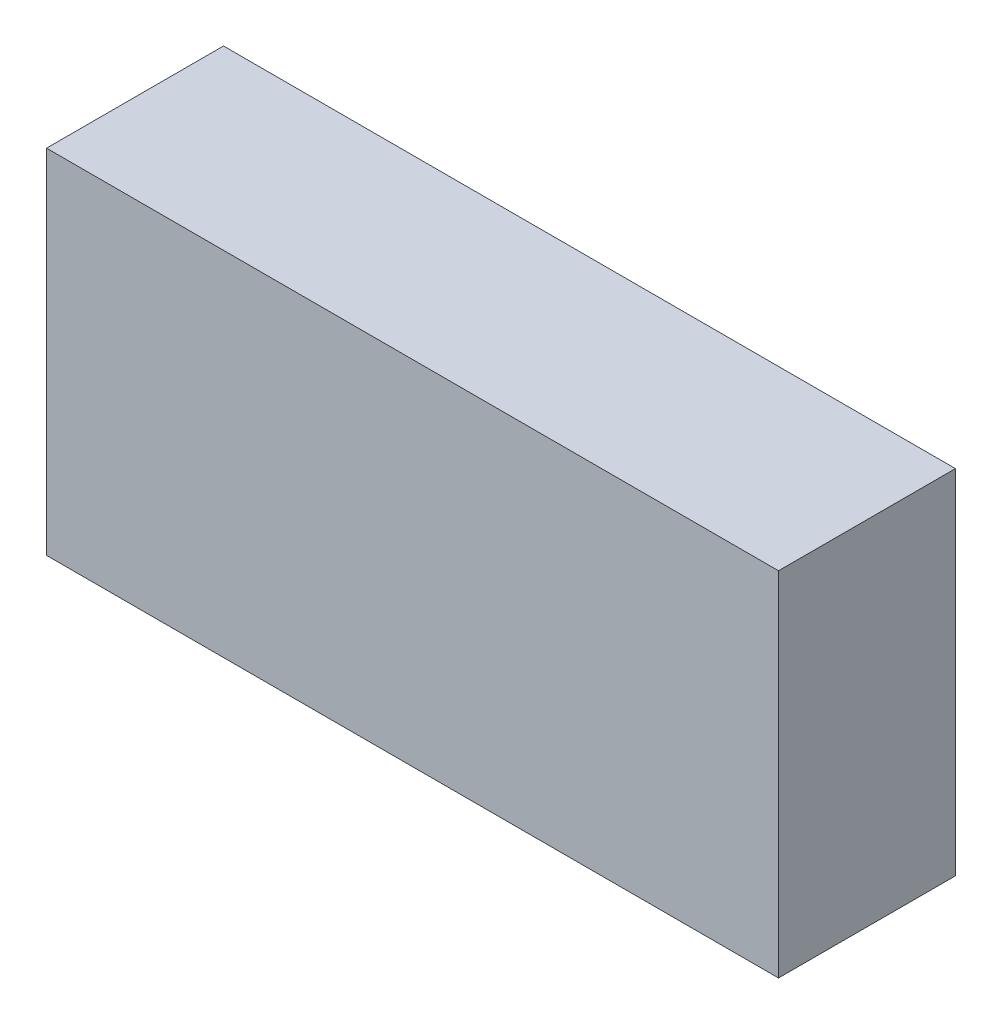
from build123d import *

# Parameters (mm, degrees)
SKETCH1_W           = 202
SKETCH1_H           = 97.33
BOSS_EXTRUDE1_DEPTH = 48.83


with BuildPart() as part:
    # Sketch1 → Boss-Extrude1 (new body)
    with BuildSketch(Plane.XY):
        with Locations((101, 48.665)):
            Rectangle(SKETCH1_W, SKETCH1_H)
    extrude(amount=BOSS_EXTRUDE1_DEPTH)


solid = part.part
